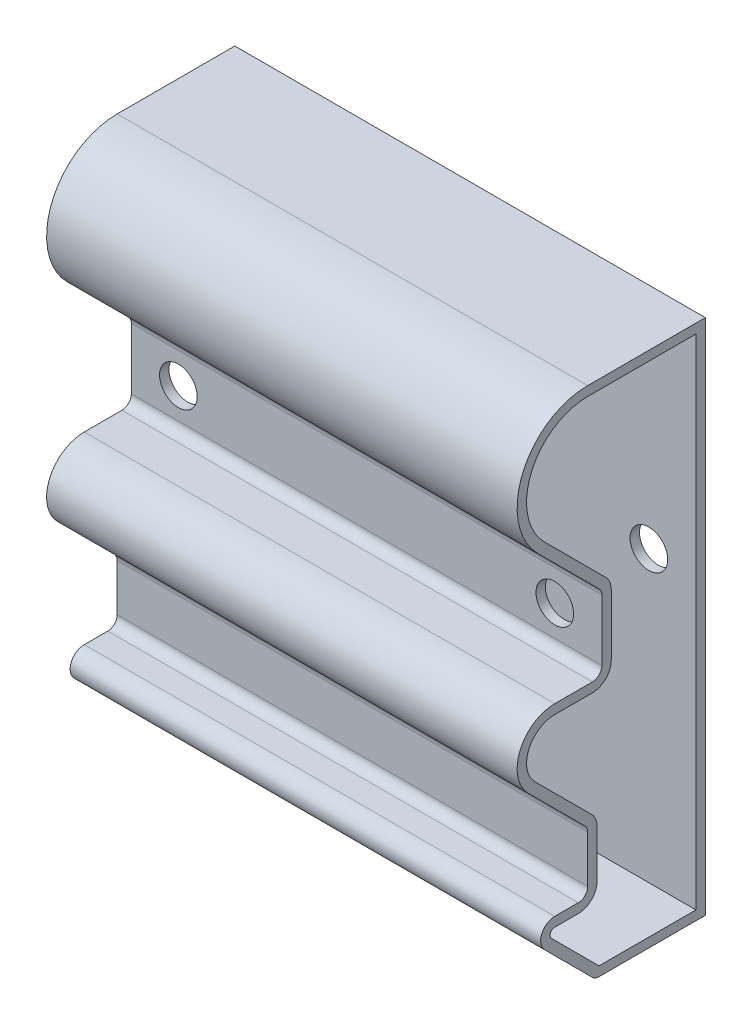
from build123d import *

# Parameters (mm, degrees)
SALIENTE_EXTRUIR1_DEPTH = 100
CROQUIS2_R              = 4
CORTAR_EXTRUIR1_DEPTH   = 23
CORTAR_EXTRUIR3_DEPTH   = 101


with BuildPart() as part:
    # Croquis1 → Saliente-Extruir1 (new body)
    with BuildSketch(Plane(origin=(0, 0, 0), x_dir=(0, 0, -1), z_dir=(1, 0, 0))):
        with BuildLine():
            Line((0, 0), (-22.597979746, 0))
            ThreePointArc((-22.597979746, 0), (-23.363346611, 0.152240935), (-24.012193309, 0.585786438))
            Line((-24.012193309, 0.585786438), (-34.121320344, 10.694913472))
            ThreePointArc((-34.121320344, 10.694913472), (-34.771638598, 13.964284113), (-32, 15.816233816))
            Line((-32, 15.816233816), (-27, 15.816233816))
            ThreePointArc((-27, 15.816233816), (-25.585786438, 16.402020254), (-25, 17.816233816))
            Line((-25, 17.816233816), (-25, 27.816233816))
            ThreePointArc((-25, 27.816233816), (-25.152240935, 28.581600681), (-25.585786438, 29.230447378))
            Line((-25.585786438, 29.230447378), (-37.656854249, 41.30151519))
            ThreePointArc((-37.656854249, 41.30151519), (-39.39103626, 50.019836899), (-32, 54.95836944))
            Line((-32, 54.95836944), (-24, 54.95836944))
            ThreePointArc((-24, 54.95836944), (-22.585786438, 55.544155877), (-22, 56.95836944))
            Line((-22, 56.95836944), (-22, 69.95836944))
            ThreePointArc((-22, 69.95836944), (-22.152240935, 70.723736304), (-22.585786438, 71.372583002))
            Line((-22.585786438, 71.372583002), (-35.606601718, 84.393398282))
            ThreePointArc((-35.606601718, 84.393398282), (-38.858192988, 100.740251485), (-25, 110))
            Line((-25, 110), (0, 110))
            Line((0, 110), (0, 0))
        make_face()
    extrude(amount=SALIENTE_EXTRUIR1_DEPTH)

    # Croquis2 → Cortar-Extruir1 (cut, through all)
    with BuildSketch(Plane.XY.offset(22)):
        with Locations((10, 63.45836944)):
            Circle(CROQUIS2_R)
        with Locations((90, 63.45836944)):
            Circle(CROQUIS2_R)
    extrude(amount=-CORTAR_EXTRUIR1_DEPTH, mode=Mode.SUBTRACT)

    # Croquis3 → Cortar-Extruir3 (cut, through all)
    with BuildSketch(Plane(origin=(100, 0, 0), x_dir=(0, 0, -1), z_dir=(1, 0, 0))):
        with BuildLine():
            Line((-24, 52.95836944), (-32, 52.95836944))
            ThreePointArc((-32, 52.95836944), (-37.543277195, 49.254470034), (-36.242640687, 42.715728753))
            Line((-36.242640687, 42.715728753), (-24.171572875, 30.644660941))
            ThreePointArc((-24.171572875, 30.644660941), (-23.30448187, 29.346967545), (-23, 27.816233816))
            Line((-23, 27.816233816), (-23, 17.816233816))
            ThreePointArc((-23, 17.816233816), (-24.171572875, 14.987806691), (-27, 13.816233816))
            Line((-27, 13.816233816), (-32, 13.816233816))
            ThreePointArc((-32, 13.816233816), (-32.923879533, 13.198917248), (-32.707106781, 12.109127035))
            Line((-32.707106781, 12.109127035), (-22.597979746, 2))
            Line((-22.597979746, 2), (-2, 2))
            Line((-2, 2), (-2, 108))
            Line((-2, 108), (-25, 108))
            ThreePointArc((-25, 108), (-37.010433923, 99.974884621), (-34.192388155, 85.807611845))
            Line((-34.192388155, 85.807611845), (-21.171572875, 72.786796564))
            ThreePointArc((-21.171572875, 72.786796564), (-20.30448187, 71.489103169), (-20, 69.95836944))
            Line((-20, 69.95836944), (-20, 56.95836944))
            ThreePointArc((-20, 56.95836944), (-21.171572875, 54.129942315), (-24, 52.95836944))
        make_face()
    extrude(amount=-CORTAR_EXTRUIR3_DEPTH, mode=Mode.SUBTRACT)


solid = part.part
